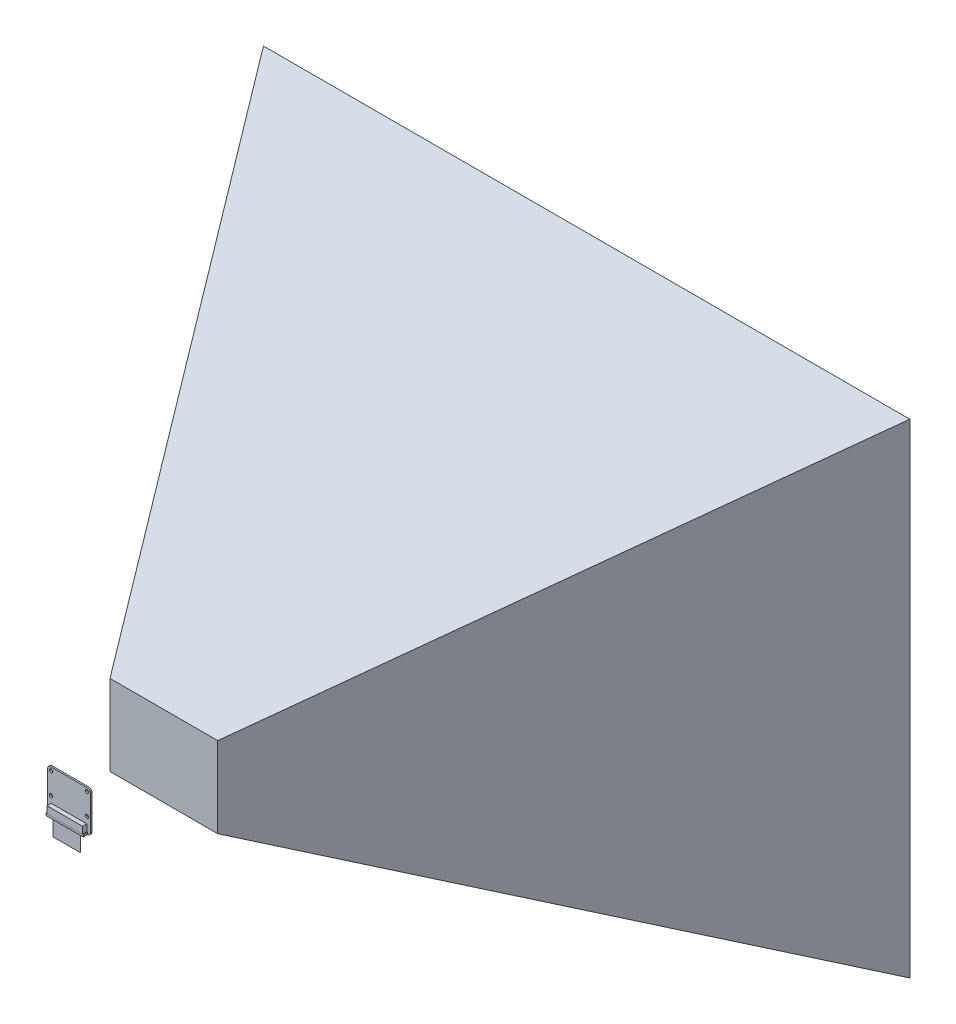
from build123d import *

# Parameters (mm, degrees)
SKETCH1_R           = 1
BOSS_EXTRUDE1_DEPTH = 0.9
SKETCH1_3_W         = 8.6
SKETCH1_3_H         = 8.6
SKETCH1_3_R         = 2.75
BOSS_EXTRUDE2_DEPTH = 5.2
SKETCH1_4_R         = 2.75
SKETCH1_4_R_2       = 0.65
BOSS_EXTRUDE3_DEPTH = 5.2
SKETCH1_5_R         = 0.65
BOSS_EXTRUDE4_DEPTH = 5.2
SKETCH3_W           = 21
SKETCH3_H           = 4.1
BOSS_EXTRUDE5_DEPTH = 2.5
BOSS_EXTRUDE6_DEPTH = 2.5
SKETCH4_W           = 16
SKETCH4_H           = 0.2
BOSS_EXTRUDE7_DEPTH = 10
SKETCH9_W           = 9.3
SKETCH9_H           = 4.1
BOSS_EXTRUDE8_DEPTH = 1.5


with BuildPart() as part:
    # Sketch1 → Boss-Extrude1 (new body)
    with BuildSketch(Plane.XY):
        with BuildLine():
            ThreePointArc((-12.6, -10.4), (-12.160660172, -11.460660172), (-11.1, -11.9))
            Line((-11.1, -11.9), (11.1, -11.9))
            ThreePointArc((11.1, -11.9), (12.160660172, -11.460660172), (12.6, -10.4))
            Line((12.6, -10.4), (12.6, 10.4))
            ThreePointArc((12.6, 10.4), (12.160660172, 11.460660172), (11.1, 11.9))
            Line((11.1, 11.9), (-11.1, 11.9))
            ThreePointArc((-11.1, 11.9), (-12.160660172, 11.460660172), (-12.6, 10.4))
            Line((-12.6, 10.4), (-12.6, -10.4))
        make_face()
        with Locations((-10.6, -2.8)):
            Circle(SKETCH1_R, mode=Mode.SUBTRACT)
        with Locations((10.6, -2.8)):
            Circle(SKETCH1_R, mode=Mode.SUBTRACT)
        with Locations((-10.6, 9.9)):
            Circle(SKETCH1_R, mode=Mode.SUBTRACT)
        with Locations((10.6, 9.9)):
            Circle(SKETCH1_R, mode=Mode.SUBTRACT)
    extrude(amount=BOSS_EXTRUDE1_DEPTH)

    # Sketch1_3 → Boss-Extrude2 (add)
    with BuildSketch(Plane.XY):
        with Locations((0, -5.3)):
            Rectangle(SKETCH1_3_W, SKETCH1_3_H)
        with Locations((0, -5.3)):
            Circle(SKETCH1_3_R, mode=Mode.SUBTRACT)
    extrude(amount=-BOSS_EXTRUDE2_DEPTH)

    # Sketch3 → Boss-Extrude5 (add)
    with BuildSketch(Plane.XY.offset(0.9)):
        with Locations((0, -8.75)):
            Rectangle(SKETCH3_W, SKETCH3_H)
    extrude(amount=BOSS_EXTRUDE5_DEPTH)

    # Sketch9 → Boss-Extrude8 (add)
    with BuildSketch(Plane(origin=(0, 0, 0), x_dir=(-1, 0, 0), z_dir=(0, 0, -1))):
        with Locations((-1.75, 6.95)):
            Rectangle(SKETCH9_W, SKETCH9_H)
    extrude(amount=BOSS_EXTRUDE8_DEPTH)


with BuildPart() as body_2:
    # Sketch1_4 → Boss-Extrude3 (new body)
    with BuildSketch(Plane.XY):
        with Locations((0, -5.3)):
            Circle(SKETCH1_4_R)
        with Locations((0, -5.3)):
            Circle(SKETCH1_4_R_2, mode=Mode.SUBTRACT)
    extrude(amount=-BOSS_EXTRUDE3_DEPTH)


with BuildPart() as body_3:
    # Sketch1_5 → Boss-Extrude4 (new body)
    with BuildSketch(Plane.XY):
        with Locations((0, -5.3)):
            Circle(SKETCH1_5_R)
    extrude(amount=-BOSS_EXTRUDE4_DEPTH)


with BuildPart() as body_4:
    # Sketch3_3 → Boss-Extrude6 (new body)
    with BuildSketch(Plane.XY.offset(0.9)):
        Polygon((10.5, -10.8), (-10.5, -10.8), (-11, -10.8), (-11, -12), (11, -12), (11, -10.8), align=None)
    extrude(amount=BOSS_EXTRUDE6_DEPTH)

    # Sketch4 → Boss-Extrude7 (add)
    with BuildSketch(Plane(origin=(0, -12, 0), x_dir=(-1, 0, 0), z_dir=(0, -1, 0))):
        with Locations((0, -2.15)):
            Rectangle(SKETCH4_W, SKETCH4_H)
    extrude(amount=BOSS_EXTRUDE7_DEPTH)


with BuildPart() as body_5:
    # Sketch7 → Camera FoV section 0
    with BuildSketch(Plane.XY.offset(-55.2)):
        with BuildLine():
            Line((-31.85351304, -29.148776635), (31.85351304, -29.148776635))
            Line((31.85351304, -29.148776635), (31.85351304, 18.548776635))
            Line((31.85351304, 18.548776635), (-31.85351304, 18.548776635))
            Line((-31.85351304, 18.548776635), (-31.85351304, -29.148776635))
        make_face()
    # Sketch8 → Camera FoV section 1
    with BuildSketch(Plane.XY.offset(-305.2)):
        with BuildLine():
            Line((-191.121078242, -148.392659809), (191.121078242, -148.392659809))
            Line((191.121078242, -148.392659809), (191.121078242, 137.792659809))
            Line((191.121078242, 137.792659809), (-191.121078242, 137.792659809))
            Line((-191.121078242, 137.792659809), (-191.121078242, -148.392659809))
        make_face()
    loft()


solid = Compound([part.part, body_2.part, body_3.part, body_4.part, body_5.part])
